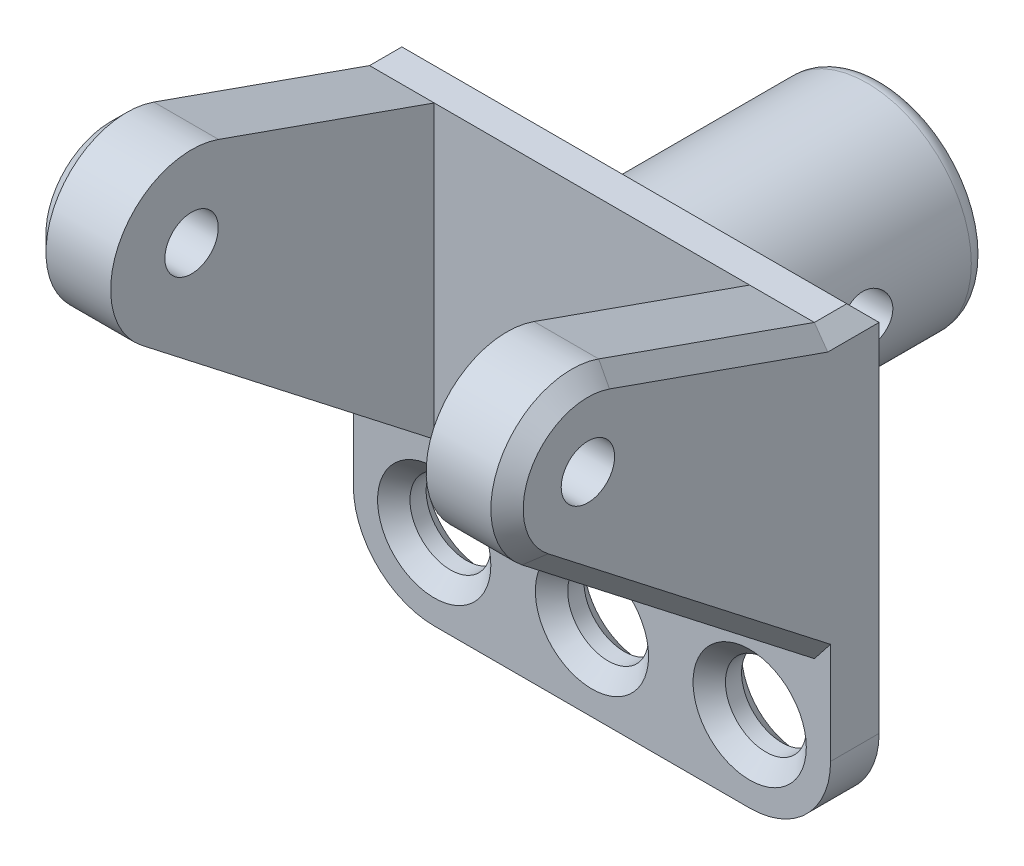
from build123d import *

# Parameters (mm, degrees)
SKETCH_1_R               = 6.45
EXTRUDE_1_DEPTH          = 15
SKETCH_2_W               = 29.5
SKETCH_2_H               = 18
EXTRUDE_2_DEPTH          = 3
EXTRUDE_START            = 14.75
SKETCH_3_R               = 1.65
EXTRUDE_3_DEPTH          = 5
EXTRUDE_START_2          = -14.75
SKETCH_3_2_R             = 1.65
EXTRUDE_4_DEPTH          = 5
EXTRUDE_5_DEPTH          = 10
FILLET_1_R               = 5
SKETCH_5_R               = 2.5
CUT_EXTRUDE_1_DEPTH      = 19
CHAMFER_1_SIZE           = 1
CHAMFER_2_SIZE           = 1
CUT_EXTRUDE_2_DEPTH      = 15.75
CUT_EXTRUDE_2_DEPTH_BACK = 15.75
FILLET_2_R               = 1


with BuildPart() as part:
    # ｽｹｯﾁ1 → ﾎﾞｽ - 押し出し1 (new body)
    with BuildSketch(Plane.XY):
        Circle(SKETCH_1_R)
    extrude(amount=EXTRUDE_1_DEPTH)

    # ｽｹｯﾁ2 → ﾎﾞｽ - 押し出し2 (add)
    with BuildSketch(Plane.XY.offset(15)):
        Rectangle(SKETCH_2_W, SKETCH_2_H)
    extrude(amount=EXTRUDE_2_DEPTH)

    # ｽｹｯﾁ3 → ﾎﾞｽ - 押し出し3 (add)
    with BuildSketch(Plane(origin=(0, 0, 0), x_dir=(0, 0, -1), z_dir=(1, 0, 0)).offset(EXTRUDE_START)):
        with BuildLine():
            Line((-18, 9), (-31.333333333, 13.714045208))
            ThreePointArc((-31.333333333, 13.714045208), (-37.386897866, 11.398984601), (-36.069570429, 5.053135753))
            Line((-36.069570429, 5.053135753), (-18, -9))
            Line((-18, -9), (-18, 9))
        make_face()
        with Locations((-33, 9)):
            Circle(SKETCH_3_R, mode=Mode.SUBTRACT)
    extrude(amount=-EXTRUDE_3_DEPTH)

    # ｽｹｯﾁ3<2> → ﾎﾞｽ - 押し出し4 (add)
    with BuildSketch(Plane(origin=(0, 0, 0), x_dir=(0, 0, -1), z_dir=(1, 0, 0)).offset(EXTRUDE_START_2)):
        with BuildLine():
            Line((-18, 9), (-31.333333333, 13.714045208))
            ThreePointArc((-31.333333333, 13.714045208), (-37.386897866, 11.398984601), (-36.069570429, 5.053135753))
            Line((-36.069570429, 5.053135753), (-18, -9))
            Line((-18, -9), (-18, 9))
        make_face()
        with Locations((-33, 9)):
            Circle(SKETCH_3_2_R, mode=Mode.SUBTRACT)
    extrude(amount=EXTRUDE_4_DEPTH)

    # ｽｹｯﾁ4 → ﾎﾞｽ - 押し出し5 (add)
    with BuildSketch(Plane.XZ.offset(9)):
        Polygon((-14.75, 15), (14.75, 15), (14.75, 18), (9.75, 18), (-9.75, 18), (-14.75, 18), align=None)
    extrude(amount=EXTRUDE_5_DEPTH)

    # ﾌｨﾚｯﾄ1
    fillet_1_edges = [part.edges().sort_by_distance(p)[0] for p in [
        (-14.75, -19, 16.5),
        (14.75, -19, 16.5),
    ]]
    fillet(fillet_1_edges, radius=FILLET_1_R)

    # ｽｹｯﾁ5 → ｶｯﾄ - 押し出し1 (cut, through all)
    with BuildSketch(Plane.XY.offset(18)):
        with Locations((0, -14)):
            Circle(SKETCH_5_R)
        with Locations((-9.75, -14)):
            Circle(SKETCH_5_R)
        with Locations((9.75, -14)):
            Circle(SKETCH_5_R)
    extrude(amount=-CUT_EXTRUDE_1_DEPTH, mode=Mode.SUBTRACT)

    # 面取り1
    chamfer_1_edges = [part.edges().sort_by_distance(p)[0] for p in [
        (7.25, -14, 15),
        (7.25, -14, 18),
        (-12.25, -14, 15),
        (-12.25, -14, 18),
        (-2.5, -14, 15),
        (-2.5, -14, 18),
    ]]
    chamfer(chamfer_1_edges, length=CHAMFER_1_SIZE)

    # 面取り2
    chamfer_2_edges = [part.edges().sort_by_distance(p)[0] for p in [
        (-14.75, 9, 16.5),
        (0, 9, 15),
        (14.75, 9, 16.5),
        (-14.75, 11.357022604, 24.666666667),
        (-14.75, 11.398984601, 37.386897866),
        (-14.75, -1.973432123, 27.034785215),
        (14.75, 11.357022604, 24.666666667),
        (14.75, 11.398984601, 37.386897866),
        (14.75, -1.973432123, 27.034785215),
    ]]
    chamfer(chamfer_2_edges, length=CHAMFER_2_SIZE)

    # ｽｹｯﾁ6 → ｶｯﾄ - 押し出し2 (cut, two sides)
    with BuildSketch(Plane(origin=(0, 0, 0), x_dir=(0, 0, -1), z_dir=(1, 0, 0))) as cut_extrude_2_sk:
        with BuildLine():
            Line((-8.928941916, -0.825), (-9.405255888, 0))
            Line((-9.405255888, 0), (-8.928941916, 0.825))
            ThreePointArc((-8.928941916, 0.825), (-5.85, 0), (-8.928941916, -0.825))
        make_face()
    extrude(amount=CUT_EXTRUDE_2_DEPTH, mode=Mode.SUBTRACT)
    extrude(cut_extrude_2_sk.sketch, amount=-CUT_EXTRUDE_2_DEPTH_BACK, mode=Mode.SUBTRACT)

    # ﾌｨﾚｯﾄ2
    fillet_2_edges = [part.edges().sort_by_distance(p)[0] for p in [
        (-6.45, 0, 0),
    ]]
    fillet(fillet_2_edges, radius=FILLET_2_R)


solid = part.part
